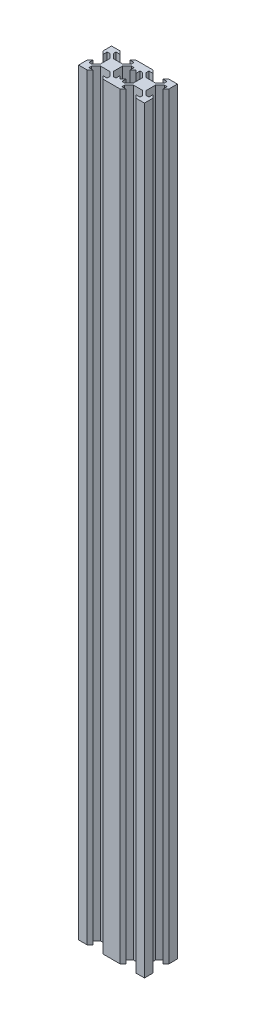
from build123d import *

# Parameters (mm, degrees)
BOSS_EXTRUDE1_DEPTH = 460
LPATTERN1_COUNT     = 2
LPATTERN1_PITCH     = 20


with BuildPart() as part:
    # Sketch1 → Boss-Extrude1 (new body)
    with BuildSketch(Plane(origin=(0, 0, 0), x_dir=(1, 0, 0), z_dir=(0, 1, 0))):
        Polygon((2.84, -3.900660172), (-2.84, -3.900660172), (-5.499339828, -6.56), (-5.499339828, -8.2), (-3.1, -8.2), (-4.9, -10), (-10, -10), (-10, -4.9), (-8.2, -3.1), (-8.2, -5.499339828), (-6.56, -5.499339828), (-3.900660172, -2.84), (-3.900660172, 2.84), (-6.56, 5.499339828), (-8.2, 5.499339828), (-8.2, 3.1), (-10, 4.9), (-10, 10), (-4.9, 10), (-3.1, 8.2), (-5.499339828, 8.2), (-5.499339828, 6.56), (-2.84, 3.900660172), (2.84, 3.900660172), (5.499339828, 6.56), (5.499339828, 8.2), (3.1, 8.2), (4.9, 10), (10, 10), (10, 4.9), (8.2, 3.1), (8.2, 5.499339828), (6.56, 5.499339828), (3.900660172, 2.84), (3.900660172, -2.84), (6.56, -5.499339828), (8.2, -5.499339828), (8.2, -3.1), (10, -4.9), (10, -10), (4.9, -10), (3.1, -8.2), (5.499339828, -8.2), (5.499339828, -6.56), align=None)
    boss_extrude1 = extrude(amount=BOSS_EXTRUDE1_DEPTH)

    # LPattern1: Boss-Extrude1 ×2
    with Locations(*[(i * LPATTERN1_PITCH, 0, 0) for i in range(1, LPATTERN1_COUNT)]):
        add(boss_extrude1)


solid = part.part
